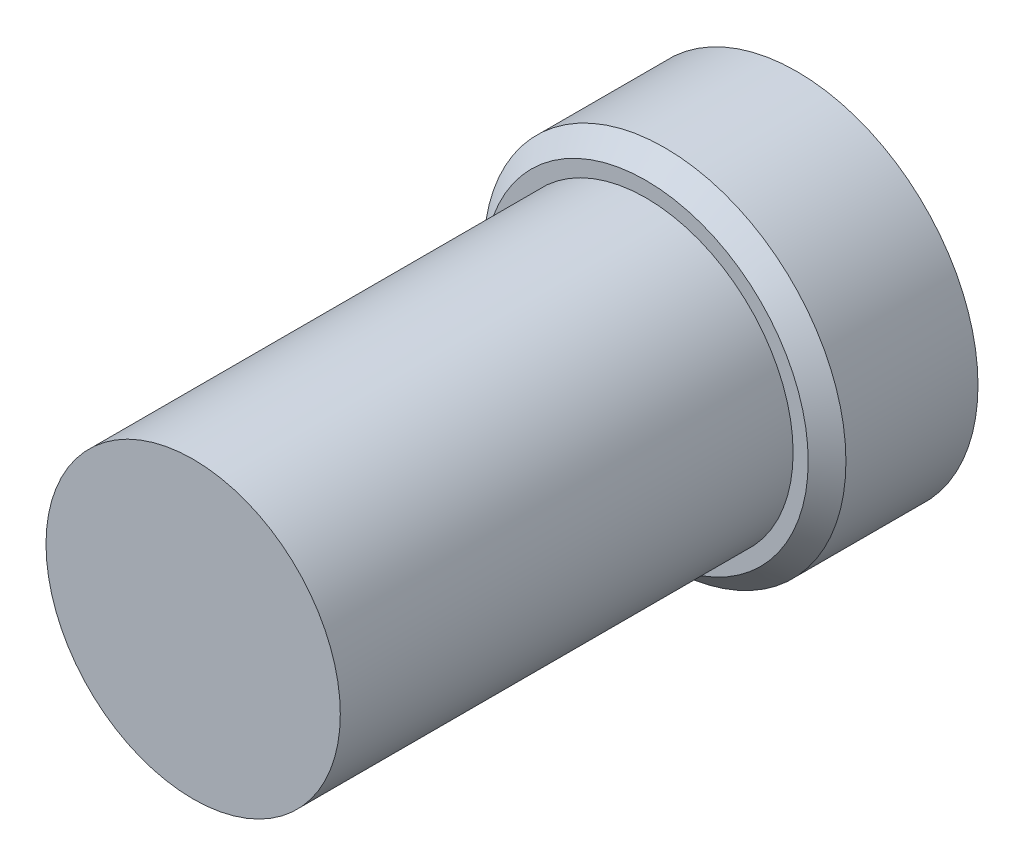
from build123d import *

# Parameters (mm, degrees)
SKETCH_1_R      = 2.4
EXTRUDE_1_DEPTH = 2
SKETCH_2_R      = 1.95
EXTRUDE_2_DEPTH = 6
CHAMFER_1_SIZE  = 0.25


with BuildPart() as part:
    # 草图1 → 拉伸1 (new body)
    with BuildSketch(Plane.XY):
        Circle(SKETCH_1_R)
    extrude(amount=EXTRUDE_1_DEPTH)

    # 草图2 → 拉伸2 (add)
    with BuildSketch(Plane.XY.offset(2)):
        Circle(SKETCH_2_R)
    extrude(amount=EXTRUDE_2_DEPTH)

    # 倒角1
    chamfer_1_edges = [part.edges().sort_by_distance(p)[0] for p in [
        (-2.4, 0, 2),
    ]]
    chamfer(chamfer_1_edges, length=CHAMFER_1_SIZE)


solid = part.part
